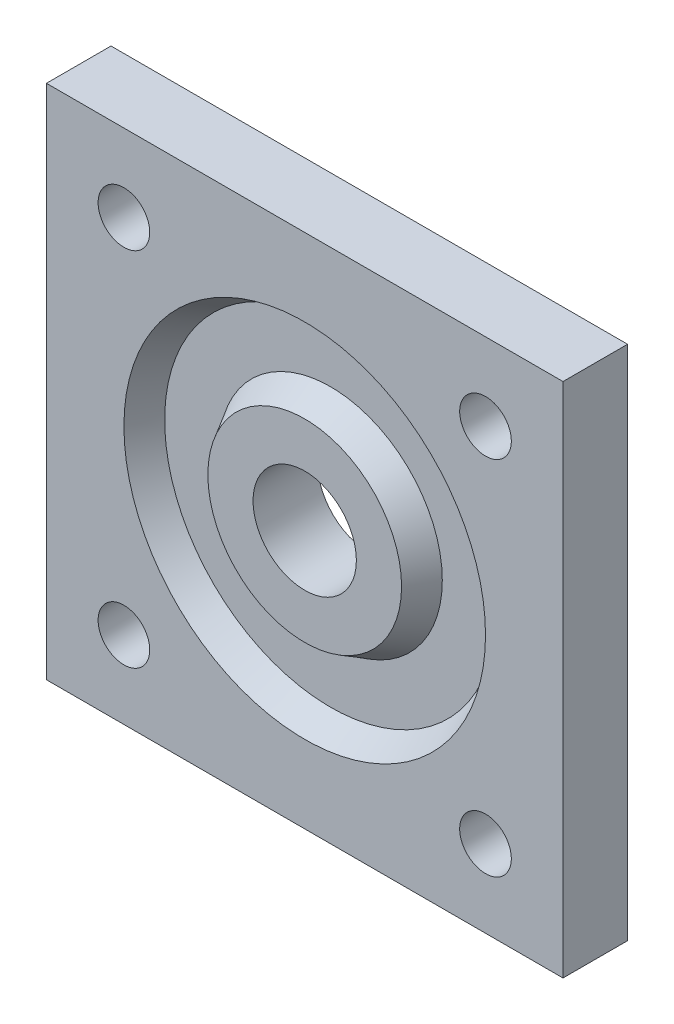
from build123d import *

# Parameters (mm, degrees)
SKETCH1_W           = 40
SKETCH1_H           = 40
BOSS_EXTRUDE1_DEPTH = 5
SKETCH2_R           = 14
SKETCH2_R_2         = 7.5
CUT_EXTRUDE1_DEPTH  = 2
CUT_EXTRUDE1_TAPER  = 30
SKETCH3_R           = 4
CUT_EXTRUDE2_DEPTH  = 6
SKETCH4_R           = 2
CUT_EXTRUDE3_DEPTH  = 6


with BuildPart() as part:
    # Sketch1 → Boss-Extrude1 (new body)
    with BuildSketch(Plane.XY):
        Rectangle(SKETCH1_W, SKETCH1_H)
    extrude(amount=BOSS_EXTRUDE1_DEPTH)

    # Sketch2 → Cut-Extrude1 (cut)
    with BuildSketch(Plane.XY.offset(5)):
        Circle(SKETCH2_R)
        Circle(SKETCH2_R_2, mode=Mode.SUBTRACT)
    extrude(amount=-CUT_EXTRUDE1_DEPTH, taper=CUT_EXTRUDE1_TAPER, mode=Mode.SUBTRACT)

    # Sketch3 → Cut-Extrude2 (cut, through all)
    with BuildSketch(Plane.XY.offset(5)):
        Circle(SKETCH3_R)
    extrude(amount=-CUT_EXTRUDE2_DEPTH, mode=Mode.SUBTRACT)

    # Sketch4 → Cut-Extrude3 (cut, through all)
    with BuildSketch(Plane.XY.offset(5)):
        with Locations((-14, 14)):
            Circle(SKETCH4_R)
        with Locations((14, 14)):
            Circle(SKETCH4_R)
        with Locations((14, -14)):
            Circle(SKETCH4_R)
        with Locations((-14, -14)):
            Circle(SKETCH4_R)
    extrude(amount=-CUT_EXTRUDE3_DEPTH, mode=Mode.SUBTRACT)


solid = part.part
